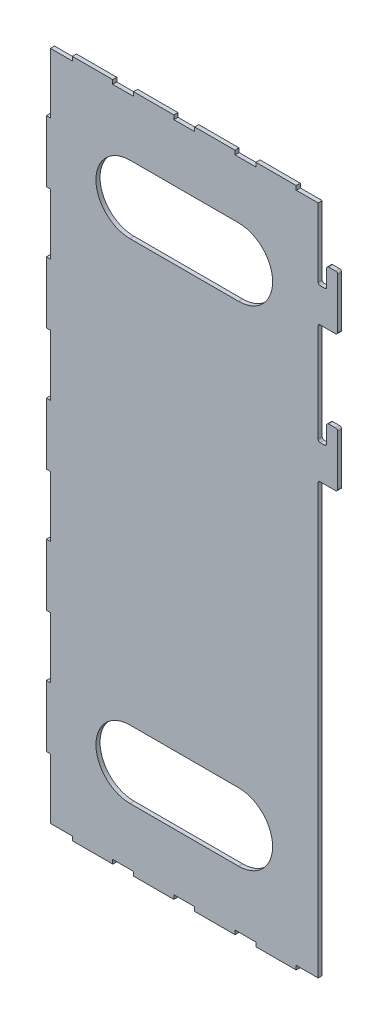
from build123d import *

# Parameters (mm, degrees)
SALIENTE_EXTRUIR1_DEPTH = 3
CORTAR_EXTRUIR1_REACH   = 5
CROQUIS2_W              = 15.3
CROQUIS2_H              = 3
CROQUIS2_W_2            = 16.15
CROQUIS2_W_3            = 3
CROQUIS2_H_2            = 44.7


with BuildPart() as part:
    # Croquis1 → Saliente-Extruir1 (new body)
    with BuildSketch(Plane.XY):
        with BuildLine():
            Line((104.8, 195), (101.5, 195))
            ThreePointArc((101.5, 195), (100.439339828, 195.439339828), (100, 196.5))
            Line((100, 196.5), (100, 250))
            Line((100, 250), (-100, 250))
            Line((-100, 250), (-100, -250))
            Line((-100, -250), (100, -250))
            Line((100, -250), (100, -35.619856886))
            Line((100, -35.619856886), (100, -30))
            Line((100, -30), (100, -5))
            Line((100, -5), (100, 68.5))
            ThreePointArc((100, 68.5), (100.439339828, 69.560660172), (101.5, 70))
            Line((101.5, 70), (112.8, 70))
            ThreePointArc((112.8, 70), (113.860660172, 70.439339828), (114.3, 71.5))
            Line((114.3, 71.5), (114.3, 108.5))
            ThreePointArc((114.3, 108.5), (113.860660172, 109.560660172), (112.8, 110))
            Line((112.8, 110), (107.8, 110))
            ThreePointArc((107.8, 110), (106.739339828, 109.560660172), (106.3, 108.5))
            Line((106.3, 108.5), (106.3, 96.5))
            ThreePointArc((106.3, 96.5), (105.860660172, 95.439339828), (104.8, 95))
            Line((104.8, 95), (101.5, 95))
            ThreePointArc((101.5, 95), (100.439339828, 95.439339828), (100, 96.5))
            Line((100, 96.5), (100, 168.5))
            ThreePointArc((100, 168.5), (100.439339828, 169.560660172), (101.5, 170))
            Line((101.5, 170), (112.8, 170))
            ThreePointArc((112.8, 170), (113.860660172, 170.439339828), (114.3, 171.5))
            Line((114.3, 171.5), (114.3, 208.5))
            ThreePointArc((114.3, 208.5), (113.860660172, 209.560660172), (112.8, 210))
            Line((112.8, 210), (107.8, 210))
            ThreePointArc((107.8, 210), (106.739339828, 209.560660172), (106.3, 208.5))
            Line((106.3, 208.5), (106.3, 196.5))
            ThreePointArc((106.3, 196.5), (105.860660172, 195.439339828), (104.8, 195))
        make_face()
    extrude(amount=SALIENTE_EXTRUIR1_DEPTH)

    # Croquis2 → Cortar-Extruir1 (cut, up to next)
    with BuildSketch(Plane.XY.offset(3), mode=Mode.PRIVATE) as cortar_extruir1_sk1:
        Polygon((-100, -250), (-80.85, -250), (-80.85, -247), (-97, -247), (-97, -202.65), (-100, -202.65), align=None)
    cortar_extruir1_tool1 = extrude(cortar_extruir1_sk1.sketch, amount=-CORTAR_EXTRUIR1_REACH, mode=Mode.PRIVATE) & part.part
    add(cortar_extruir1_tool1.solids().sort_by_distance((-99.489241, -226.325, 3))[0], mode=Mode.SUBTRACT)
    # Croquis2 → Cortar-Extruir1 (cut, up to next)
    with BuildSketch(Plane.XY.offset(3), mode=Mode.PRIVATE) as cortar_extruir1_sk2:
        with Locations((-43.5, -248.5)):
            Rectangle(CROQUIS2_W, CROQUIS2_H)
    cortar_extruir1_tool2 = extrude(cortar_extruir1_sk2.sketch, amount=-CORTAR_EXTRUIR1_REACH, mode=Mode.PRIVATE) & part.part
    add(cortar_extruir1_tool2.solids().sort_by_distance((-43.5, -248.5, 3))[0], mode=Mode.SUBTRACT)
    # Croquis2 → Cortar-Extruir1 (cut, up to next)
    with BuildSketch(Plane.XY.offset(3), mode=Mode.PRIVATE) as cortar_extruir1_sk3:
        with Locations((1.5, -248.5)):
            Rectangle(CROQUIS2_W, CROQUIS2_H)
    cortar_extruir1_tool3 = extrude(cortar_extruir1_sk3.sketch, amount=-CORTAR_EXTRUIR1_REACH, mode=Mode.PRIVATE) & part.part
    add(cortar_extruir1_tool3.solids().sort_by_distance((1.5, -248.5, 3))[0], mode=Mode.SUBTRACT)
    # Croquis2 → Cortar-Extruir1 (cut, up to next)
    with BuildSketch(Plane.XY.offset(3), mode=Mode.PRIVATE) as cortar_extruir1_sk4:
        with Locations((46.5, -248.5)):
            Rectangle(CROQUIS2_W, CROQUIS2_H)
    cortar_extruir1_tool4 = extrude(cortar_extruir1_sk4.sketch, amount=-CORTAR_EXTRUIR1_REACH, mode=Mode.PRIVATE) & part.part
    add(cortar_extruir1_tool4.solids().sort_by_distance((46.5, -248.5, 3))[0], mode=Mode.SUBTRACT)
    # Croquis2 → Cortar-Extruir1 (cut, up to next)
    with BuildSketch(Plane.XY.offset(3), mode=Mode.PRIVATE) as cortar_extruir1_sk5:
        with Locations((91.925, -248.5)):
            Rectangle(CROQUIS2_W_2, CROQUIS2_H)
    cortar_extruir1_tool5 = extrude(cortar_extruir1_sk5.sketch, amount=-CORTAR_EXTRUIR1_REACH, mode=Mode.PRIVATE) & part.part
    add(cortar_extruir1_tool5.solids().sort_by_distance((91.925, -248.5, 3))[0], mode=Mode.SUBTRACT)
    # Croquis2 → Cortar-Extruir1 (cut, up to next)
    with BuildSketch(Plane.XY.offset(3), mode=Mode.PRIVATE) as cortar_extruir1_sk6:
        with Locations((-98.5, -135)):
            Rectangle(CROQUIS2_W_3, CROQUIS2_H_2)
    cortar_extruir1_tool6 = extrude(cortar_extruir1_sk6.sketch, amount=-CORTAR_EXTRUIR1_REACH, mode=Mode.PRIVATE) & part.part
    add(cortar_extruir1_tool6.solids().sort_by_distance((-98.5, -135, 3))[0], mode=Mode.SUBTRACT)
    # Croquis2 → Cortar-Extruir1 (cut, up to next)
    with BuildSketch(Plane.XY.offset(3), mode=Mode.PRIVATE) as cortar_extruir1_sk7:
        with Locations((-98.5, -45)):
            Rectangle(CROQUIS2_W_3, CROQUIS2_H_2)
    cortar_extruir1_tool7 = extrude(cortar_extruir1_sk7.sketch, amount=-CORTAR_EXTRUIR1_REACH, mode=Mode.PRIVATE) & part.part
    add(cortar_extruir1_tool7.solids().sort_by_distance((-98.5, -45, 3))[0], mode=Mode.SUBTRACT)
    # Croquis2 → Cortar-Extruir1 (cut, up to next)
    with BuildSketch(Plane.XY.offset(3), mode=Mode.PRIVATE) as cortar_extruir1_sk8:
        with Locations((-98.5, 45)):
            Rectangle(CROQUIS2_W_3, CROQUIS2_H_2)
    cortar_extruir1_tool8 = extrude(cortar_extruir1_sk8.sketch, amount=-CORTAR_EXTRUIR1_REACH, mode=Mode.PRIVATE) & part.part
    add(cortar_extruir1_tool8.solids().sort_by_distance((-98.5, 45, 3))[0], mode=Mode.SUBTRACT)
    # Croquis2 → Cortar-Extruir1 (cut, up to next)
    with BuildSketch(Plane.XY.offset(3), mode=Mode.PRIVATE) as cortar_extruir1_sk9:
        with Locations((-98.5, 135)):
            Rectangle(CROQUIS2_W_3, CROQUIS2_H_2)
    cortar_extruir1_tool9 = extrude(cortar_extruir1_sk9.sketch, amount=-CORTAR_EXTRUIR1_REACH, mode=Mode.PRIVATE) & part.part
    add(cortar_extruir1_tool9.solids().sort_by_distance((-98.5, 135, 3))[0], mode=Mode.SUBTRACT)
    # Croquis2 → Cortar-Extruir1 (cut, up to next)
    with BuildSketch(Plane.XY.offset(3), mode=Mode.PRIVATE) as cortar_extruir1_sk10:
        Polygon((-80.85, 247), (-80.85, 250), (-100, 250), (-100, 202.65), (-97, 202.65), (-97, 247), align=None)
    cortar_extruir1_tool10 = extrude(cortar_extruir1_sk10.sketch, amount=-CORTAR_EXTRUIR1_REACH, mode=Mode.PRIVATE) & part.part
    add(cortar_extruir1_tool10.solids().sort_by_distance((-81.360759, 248.5, 3))[0], mode=Mode.SUBTRACT)
    # Croquis2 → Cortar-Extruir1 (cut, up to next)
    with BuildSketch(Plane.XY.offset(3), mode=Mode.PRIVATE) as cortar_extruir1_sk11:
        with Locations((-43.5, 248.5)):
            Rectangle(CROQUIS2_W, CROQUIS2_H)
    cortar_extruir1_tool11 = extrude(cortar_extruir1_sk11.sketch, amount=-CORTAR_EXTRUIR1_REACH, mode=Mode.PRIVATE) & part.part
    add(cortar_extruir1_tool11.solids().sort_by_distance((-43.5, 248.5, 3))[0], mode=Mode.SUBTRACT)
    # Croquis2 → Cortar-Extruir1 (cut, up to next)
    with BuildSketch(Plane.XY.offset(3), mode=Mode.PRIVATE) as cortar_extruir1_sk12:
        with BuildLine():
            ThreePointArc((41.5, 155), (59.17766953, 162.32233047), (66.5, 180))
            ThreePointArc((66.5, 180), (59.17766953, 197.67766953), (41.5, 205))
            Line((41.5, 205), (-38.5, 205))
            ThreePointArc((-38.5, 205), (-63.5, 180), (-38.5, 155))
            Line((-38.5, 155), (41.5, 155))
        make_face()
    cortar_extruir1_tool12 = extrude(cortar_extruir1_sk12.sketch, amount=-CORTAR_EXTRUIR1_REACH, mode=Mode.PRIVATE) & part.part
    add(cortar_extruir1_tool12.solids().sort_by_distance((1.5, 180, 3))[0], mode=Mode.SUBTRACT)
    # Croquis2 → Cortar-Extruir1 (cut, up to next)
    with BuildSketch(Plane.XY.offset(3), mode=Mode.PRIVATE) as cortar_extruir1_sk13:
        with Locations((46.5, 248.5)):
            Rectangle(CROQUIS2_W, CROQUIS2_H)
    cortar_extruir1_tool13 = extrude(cortar_extruir1_sk13.sketch, amount=-CORTAR_EXTRUIR1_REACH, mode=Mode.PRIVATE) & part.part
    add(cortar_extruir1_tool13.solids().sort_by_distance((46.5, 248.5, 3))[0], mode=Mode.SUBTRACT)
    # Croquis2 → Cortar-Extruir1 (cut, up to next)
    with BuildSketch(Plane.XY.offset(3), mode=Mode.PRIVATE) as cortar_extruir1_sk14:
        with Locations((1.5, 248.5)):
            Rectangle(CROQUIS2_W, CROQUIS2_H)
    cortar_extruir1_tool14 = extrude(cortar_extruir1_sk14.sketch, amount=-CORTAR_EXTRUIR1_REACH, mode=Mode.PRIVATE) & part.part
    add(cortar_extruir1_tool14.solids().sort_by_distance((1.5, 248.5, 3))[0], mode=Mode.SUBTRACT)
    # Croquis2 → Cortar-Extruir1 (cut, up to next)
    with BuildSketch(Plane.XY.offset(3), mode=Mode.PRIVATE) as cortar_extruir1_sk15:
        with Locations((91.925, 248.5)):
            Rectangle(CROQUIS2_W_2, CROQUIS2_H)
    cortar_extruir1_tool15 = extrude(cortar_extruir1_sk15.sketch, amount=-CORTAR_EXTRUIR1_REACH, mode=Mode.PRIVATE) & part.part
    add(cortar_extruir1_tool15.solids().sort_by_distance((91.925, 248.5, 3))[0], mode=Mode.SUBTRACT)
    # Croquis2 → Cortar-Extruir1 (cut, up to next)
    with BuildSketch(Plane.XY.offset(3), mode=Mode.PRIVATE) as cortar_extruir1_sk16:
        with BuildLine():
            ThreePointArc((41.5, -205), (59.17766953, -197.67766953), (66.5, -180))
            ThreePointArc((66.5, -180), (59.17766953, -162.32233047), (41.5, -155))
            Line((41.5, -155), (-38.5, -155))
            ThreePointArc((-38.5, -155), (-63.5, -180), (-38.5, -205))
            Line((-38.5, -205), (41.5, -205))
        make_face()
    cortar_extruir1_tool16 = extrude(cortar_extruir1_sk16.sketch, amount=-CORTAR_EXTRUIR1_REACH, mode=Mode.PRIVATE) & part.part
    add(cortar_extruir1_tool16.solids().sort_by_distance((1.5, -180, 3))[0], mode=Mode.SUBTRACT)


solid = part.part
